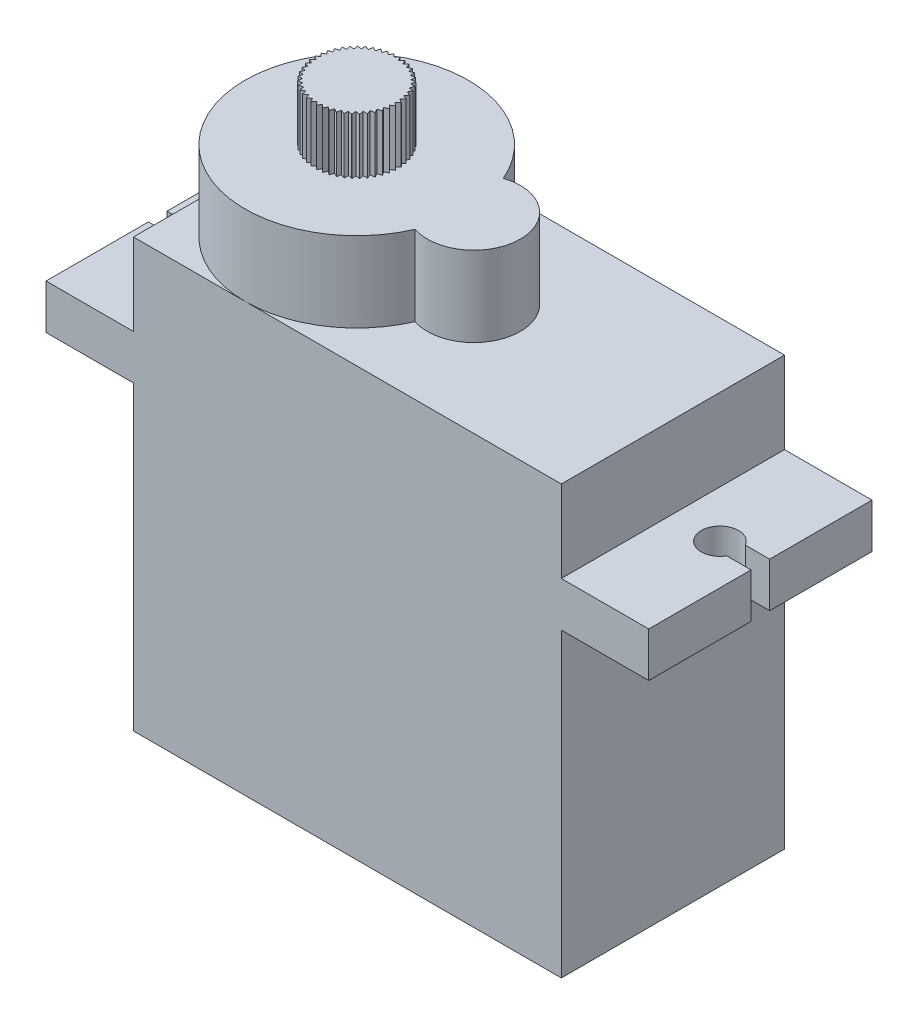
from build123d import *

# Parameters (mm, degrees)
SKETCH2_W           = 23
SKETCH2_H           = 12
BOSS_EXTRUDE1_DEPTH = 23
BOSS_EXTRUDE2_START = -4.4
BOSS_EXTRUDE2_DEPTH = 2.4
SKETCH4_R           = 6
SKETCH4_R_2         = 2.5
BOSS_EXTRUDE3_DEPTH = 4.3
BOSS_EXTRUDE4_DEPTH = 3
SKETCH6_W           = 3
SKETCH6_H           = 1
BOSS_EXTRUDE5_DEPTH = 3


with BuildPart() as part:
    # Sketch2 → Boss-Extrude1 (new body)
    with BuildSketch(Plane(origin=(0, 0, 0), x_dir=(1, 0, 0), z_dir=(0, 1, 0))):
        Rectangle(SKETCH2_W, SKETCH2_H)
    extrude(amount=-BOSS_EXTRUDE1_DEPTH)

    # Sketch3 → Boss-Extrude2 (add)
    with BuildSketch(Plane(origin=(0, 0, 0), x_dir=(1, 0, 0), z_dir=(0, 1, 0)).offset(BOSS_EXTRUDE2_START)):
        with BuildLine():
            Line((-16.2, -0.5), (-16.2, -6))
            Line((-16.2, -6), (-11.5, -6))
            Line((-11.5, -6), (-11.5, 6))
            Line((-11.5, 6), (-16.2, 6))
            Line((-16.2, 6), (-16.2, 0.5))
            Line((-16.2, 0.5), (-15.584293743, 0.5))
            ThreePointArc((-15.584293743, 0.5), (-14.459449294, 0.965925826), (-13.718268339, 0))
            ThreePointArc((-13.718268339, 0), (-14.459449294, -0.965925826), (-15.584293743, -0.5))
            Line((-15.584293743, -0.5), (-16.2, -0.5))
        make_face()
        with BuildLine():
            Line((11.5, 6), (11.5, -6))
            Line((11.5, -6), (16.2, -6))
            Line((16.2, -6), (16.2, -0.5))
            Line((16.2, -0.5), (14.894380034, -0.5))
            ThreePointArc((14.894380034, -0.5), (13.02835463, 0), (14.894380034, 0.5))
            Line((14.894380034, 0.5), (16.2, 0.5))
            Line((16.2, 0.5), (16.2, 6))
            Line((16.2, 6), (11.5, 6))
        make_face()
    extrude(amount=-BOSS_EXTRUDE2_DEPTH)

    # Sketch4 → Boss-Extrude3 (add)
    with BuildSketch(Plane(origin=(0, 0, 0), x_dir=(1, 0, 0), z_dir=(0, 1, 0))):
        with Locations((-5.5, 0)):
            Circle(SKETCH4_R)
        with Locations((0.8, 0)):
            Circle(SKETCH4_R_2)
    extrude(amount=BOSS_EXTRUDE3_DEPTH)

    # Sketch5 → Boss-Extrude4 (add)
    with BuildSketch(Plane(origin=(0, 4.3, 0), x_dir=(1, 0, 0), z_dir=(0, 1, 0))):
        Polygon((-3.255005568, -0.15), (-3.437184296, 0), (-3.255005568, 0.15), (-3.455589794, 0.274946425), (-3.295142762, 0.44844683), (-3.51047784, 0.544986424), (-3.374587739, 0.738324266), (-3.600868956, 0.805301127), (-3.491960749, 1.015026288), (-3.725150111, 1.051245213), (-3.645167266, 1.273615142), (-3.881103504, 1.278429803), (-3.831473318, 1.509476304), (-4.065946143, 1.482800783), (-4.047554268, 1.718400825), (-4.276379508, 1.660711148), (-4.289554146, 1.896660443), (-4.508648409, 1.808986083), (-4.553154459, 2.04107411), (-4.758608002, 1.924979619), (-4.833651254, 2.149064761), (-5.021797754, 2.006621847), (-5.126039057, 2.218705301), (-5.293521035, 2.052455862), (-5.425100203, 2.248752992), (-5.568928939, 2.061663752), (-5.725497937, 2.238671633), (-5.843106805, 2.034081205), (-6.021871655, 2.188641125), (-6.111161921, 1.97020043), (-6.308932561, 2.099554265), (-6.368310838, 1.871161381), (-6.581558046, 1.973000809), (-6.609964728, 1.738731414), (-6.834883102, 1.811239107), (-6.831811271, 1.575273743), (-7.064387138, 1.6171558), (-7.02989161, 1.383705275), (-7.265974648, 1.39421431), (-7.200670997, 1.167444554), (-7.436048299, 1.146393032), (-7.34110187, 0.930350756), (-7.571573122, 0.878114343), (-7.448678237, 0.676654828), (-7.670130674, 0.594165683), (-7.521480394, 0.410883978), (-7.729962192, 0.299614123), (-7.558209186, 0.137780894), (-7.749999982, -0.000284059), (-7.558209186, -0.137780894), (-7.729886469, -0.300177172), (-7.521480394, -0.410883978), (-7.669980579, -0.594713616), (-7.448678237, -0.676654828), (-7.571351335, -0.878637381), (-7.34110187, -0.930350756), (-7.435758777, -1.146881842), (-7.200670997, -1.167444554), (-7.265622557, -1.394660168), (-7.02989161, -1.383705275), (-7.063978761, -1.617550752), (-6.831811271, -1.575273743), (-6.834425728, -1.811576103), (-6.609964728, -1.738731414), (-6.581059835, -1.973273836), (-6.368310838, -1.871161381), (-6.308402404, -2.099758451), (-6.111161921, -1.97020043), (-6.021319013, -2.188772827), (-5.843106805, -2.034081205), (-5.724932672, -2.238728499), (-5.568928939, -2.061663752), (-5.424532402, -2.248734009), (-5.293521035, -2.052455862), (-5.125478853, -2.218610806), (-5.021797754, -2.006621847), (-4.833108643, -2.148896442), (-4.758608002, -1.924979619), (-4.552639125, -2.040834969), (-4.508648409, -1.808986083), (-4.289075284, -1.896354748), (-4.276379508, -1.660711148), (-4.047120423, -1.718034032), (-4.065946143, -1.482800783), (-3.831092233, -1.509054958), (-3.881103504, -1.278429803), (-3.644845742, -1.273146762), (-3.725150111, -1.051245213), (-3.491704522, -1.014519232), (-3.600868956, -0.805301127), (-3.374401382, -0.737787582), (-3.51047784, -0.544986424), (-3.295029601, -0.447890096), (-3.455589794, -0.274946425), align=None)
    extrude(amount=BOSS_EXTRUDE4_DEPTH)

    # Sketch6 → Boss-Extrude5 (add)
    with BuildSketch(Plane.ZY.offset(11.5)):
        with Locations((0, -17.5)):
            Rectangle(SKETCH6_W, SKETCH6_H)
    extrude(amount=BOSS_EXTRUDE5_DEPTH)


solid = part.part
